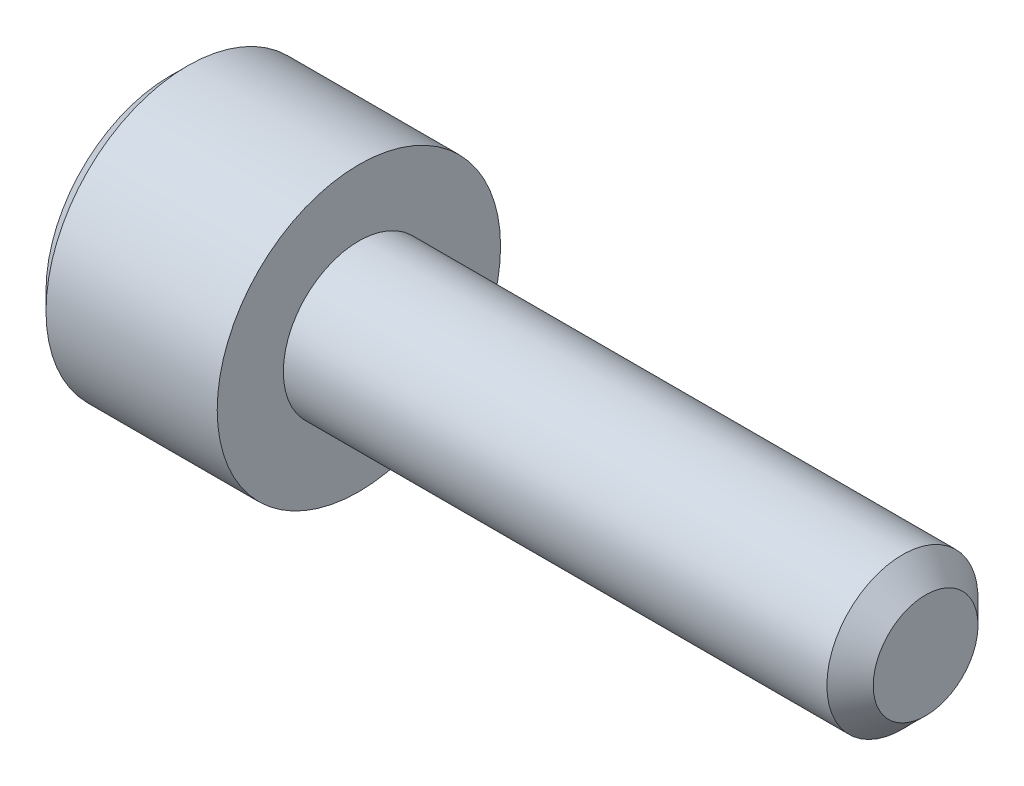
from build123d import *

# Parameters (mm, degrees)
CUT_EXTRUDE1_DEPTH = 1


with BuildPart() as part:
    # Sketch1 → Revolve1 (revolve)
    with BuildSketch(Plane.XY):
        Polygon((-2, 0), (-2, 1.3125), (-1.8125, 1.5), (0, 1.5), (0, 0.8), (5.7545, 0.8), (6, 0.5545), (6, 0), align=None)
    revolve(axis=Axis((6, 0, 0), (-1, 0, 0)))

    # Sketch2 → Cut-Revolve1 (revolve, cut)
    with BuildSketch(Plane.XY):
        Polygon((-2, 0), (-2, 0.9), (-1.85, 0.75), (-1, 0.75), (-0.6, 0), align=None)
    revolve(axis=Axis((-0.6, 0, 0), (-1, 0, 0)), mode=Mode.SUBTRACT)

    # Sketch3 → Cut-Extrude1 (cut)
    with BuildSketch(Plane(origin=(-2, 0, 0), x_dir=(0, 0, -1), z_dir=(1, 0, 0))):
        Polygon((-0.75, -0.433012702), (0, -0.866025404), (0.75, -0.433012702), (0.75, 0.433012702), (0, 0.866025404), (-0.75, 0.433012702), align=None)
    extrude(amount=CUT_EXTRUDE1_DEPTH, mode=Mode.SUBTRACT)


solid = part.part
